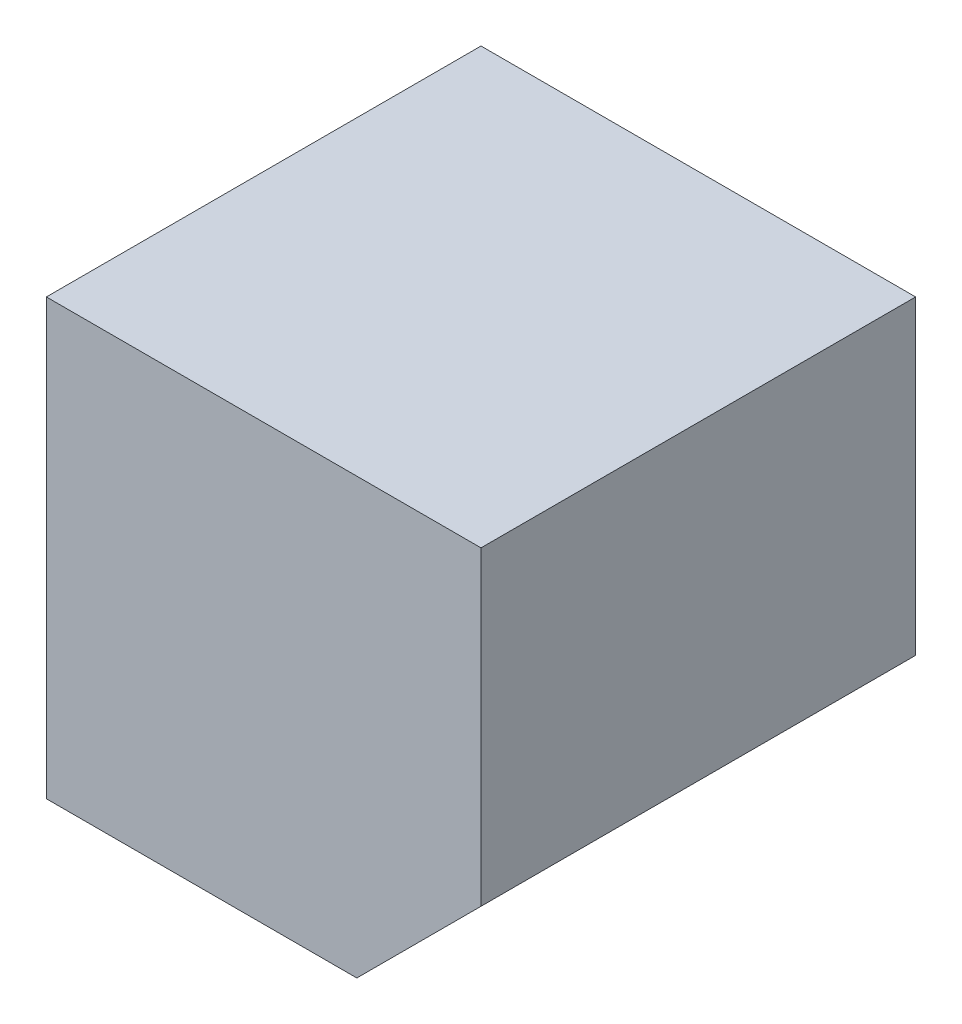
from build123d import *

# Parameters (mm, degrees)
BOSS_EXTRUDE1_DEPTH = 889


with BuildPart() as part:
    # Sketch1 → Boss-Extrude1 (new body, symmetric)
    with BuildSketch(Plane.XY):
        Polygon((381, -889), (889, -381), (889, 889), (-889, 889), (-889, -889), align=None)
    extrude(amount=BOSS_EXTRUDE1_DEPTH, both=True)


solid = part.part
